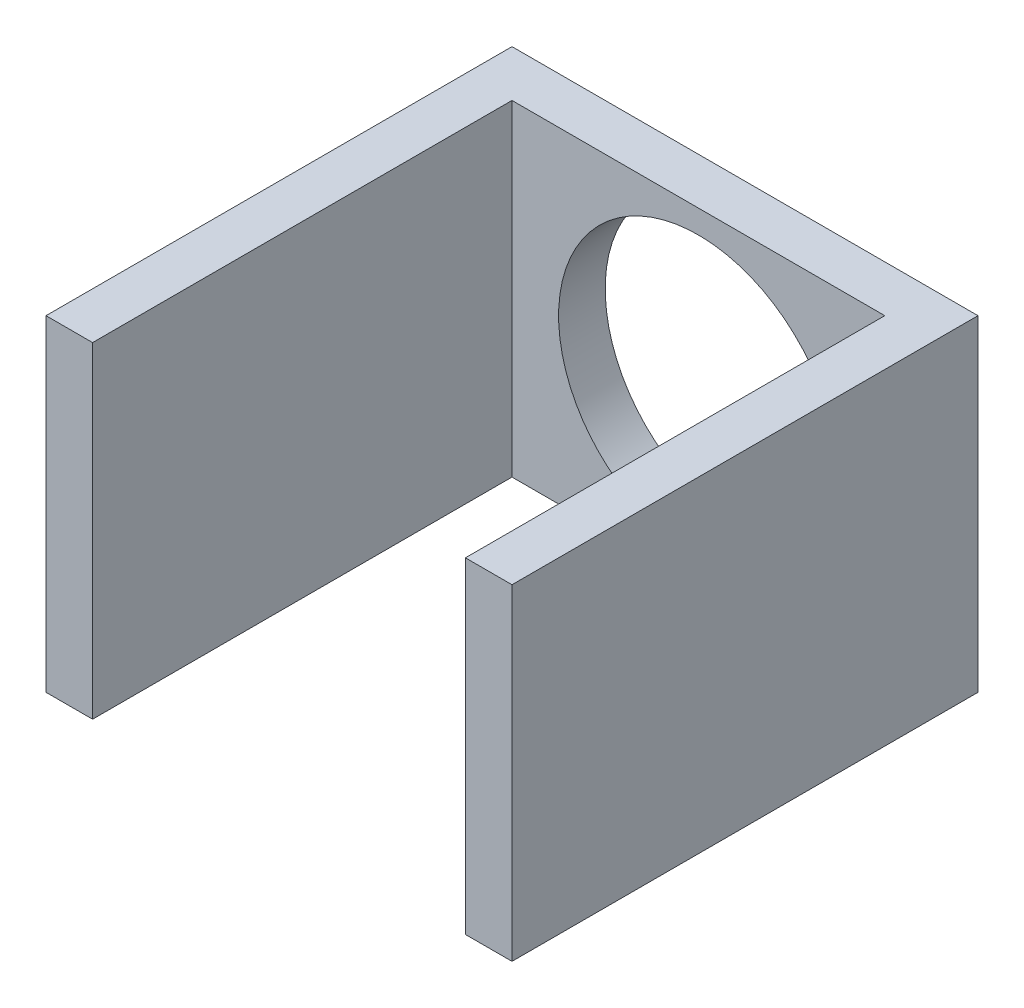
from build123d import *

# Parameters (mm, degrees)
ESQUISSE1_W             = 80
ESQUISSE1_H             = 70
BOSS_EXTRU_2_DEPTH      = 10
ESQUISSE1_4_W           = 10
ESQUISSE1_4_H           = 70
BOSS_EXTRU_3_DEPTH      = 100
ESQUISSE4_R             = 30
ENL_V_MAT_EXTRU_1_DEPTH = 10


with BuildPart() as part:
    # Esquisse1 → Boss.-Extru.2 (new body)
    with BuildSketch(Plane.XY):
        with Locations((-50, 35)):
            Rectangle(ESQUISSE1_W, ESQUISSE1_H)
    extrude(amount=BOSS_EXTRU_2_DEPTH)

    # Esquisse1_4 → Boss.-Extru.3 (add)
    with BuildSketch(Plane.XY):
        with Locations((-5, 35)):
            Rectangle(ESQUISSE1_4_W, ESQUISSE1_4_H)
        with Locations((-95, 35)):
            Rectangle(ESQUISSE1_4_W, ESQUISSE1_4_H)
    extrude(amount=BOSS_EXTRU_3_DEPTH)

    # Esquisse4 → Enlèv. mat.-Extru.1 (cut)
    with BuildSketch(Plane.XY):
        with Locations((-50, 35)):
            Circle(ESQUISSE4_R)
    extrude(amount=ENL_V_MAT_EXTRU_1_DEPTH, mode=Mode.SUBTRACT)


solid = part.part
